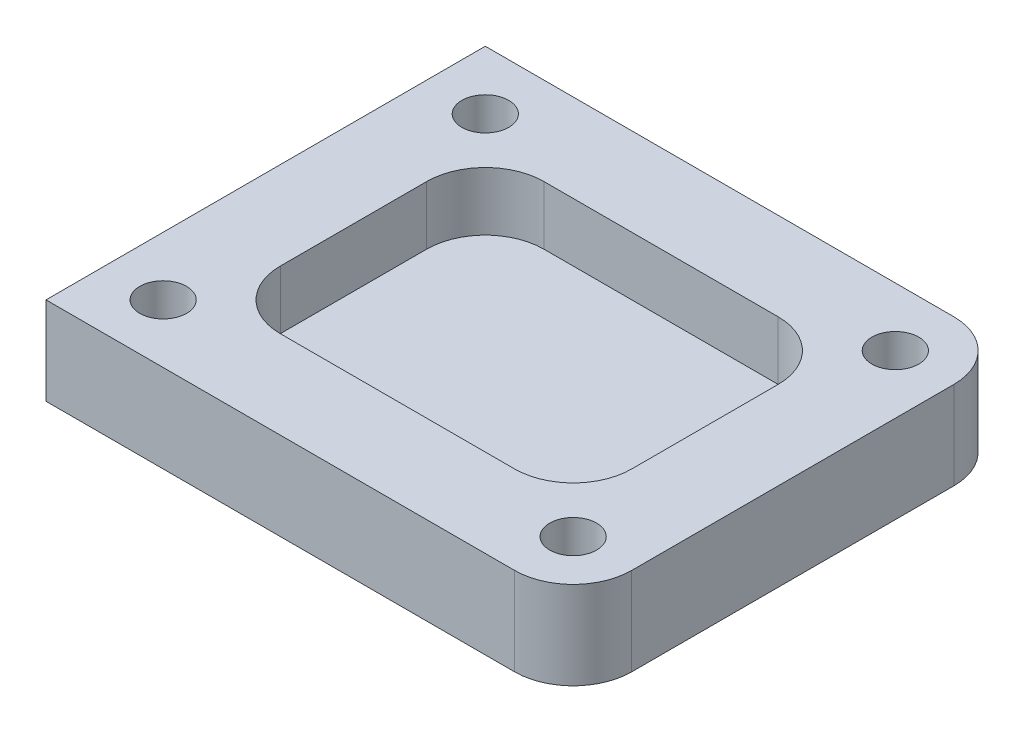
from build123d import *

# Parameters (mm, degrees)
SKETCH1_W                  = 180
SKETCH1_H                  = 150
BOSS_EXTRUDE1_DEPTH        = 30
F_16_0MM_DOWEL_HOLE1_D     = 16
F_16_0MM_DOWEL_HOLE1_DEPTH = 15
F_16_0MM_DOWEL_HOLE1_TIP   = 4.806884952
SKETCH5_W                  = 120
SKETCH5_H                  = 90
CUT_EXTRUDE1_DEPTH         = 20
FILLET1_R                  = 20
FILLET2_R                  = 20


with BuildPart() as part:
    # Sketch1 → Boss-Extrude1 (new body)
    with BuildSketch(Plane(origin=(0, 0, 0), x_dir=(1, 0, 0), z_dir=(0, 1, 0))):
        Rectangle(SKETCH1_W, SKETCH1_H)
    extrude(amount=BOSS_EXTRUDE1_DEPTH)

    # Ø16.0mm Dowel Hole1
    with Locations(Plane(origin=(-70, 30, 55), x_dir=(0, 0, 1), z_dir=(0, 1, 0))):
        with Locations((0, 0), (-110, 0), (-110, 140), (0, 140)):
            Hole(F_16_0MM_DOWEL_HOLE1_D / 2, depth=F_16_0MM_DOWEL_HOLE1_DEPTH)
            with Locations((0, 0, -(F_16_0MM_DOWEL_HOLE1_DEPTH + F_16_0MM_DOWEL_HOLE1_TIP / 2))):  # 118° drill point
                Cone(0, F_16_0MM_DOWEL_HOLE1_D / 2, F_16_0MM_DOWEL_HOLE1_TIP, mode=Mode.SUBTRACT)

    # Sketch5 → Cut-Extrude1 (cut)
    with BuildSketch(Plane(origin=(0, 30, 0), x_dir=(1, 0, 0), z_dir=(0, 1, 0))):
        Rectangle(SKETCH5_W, SKETCH5_H)
    extrude(amount=-CUT_EXTRUDE1_DEPTH, mode=Mode.SUBTRACT)

    # Fillet1
    fillet1_edges = [part.edges().sort_by_distance(p)[0] for p in [
        (60, 20, -45),
        (-60, 20, -45),
        (-60, 20, 45),
        (60, 20, 45),
    ]]
    fillet(fillet1_edges, radius=FILLET1_R)

    # Fillet2
    fillet2_edges = [part.edges().sort_by_distance(p)[0] for p in [
        (90, 15, 75),
        (90, 15, -75),
    ]]
    fillet(fillet2_edges, radius=FILLET2_R)


solid = part.part
